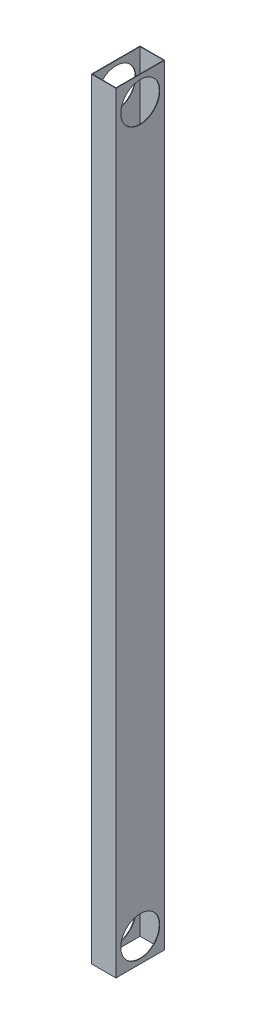
from build123d import *

# Parameters (mm, degrees)
SKETCH2_W           = 51
SKETCH2_H           = 101
SKETCH2_W_2         = 49
SKETCH2_H_2         = 99
BOSS_EXTRUDE2_DEPTH = 1600
SKETCH3_R           = 40.5
CUT_EXTRUDE2_DEPTH  = 52


with BuildPart() as part:
    # Sketch2 → Boss-Extrude2 (new body)
    with BuildSketch(Plane(origin=(0, 0, 0), x_dir=(1, 0, 0), z_dir=(0, 1, 0))):
        Rectangle(SKETCH2_W, SKETCH2_H)
        Rectangle(SKETCH2_W_2, SKETCH2_H_2, mode=Mode.SUBTRACT)
    extrude(amount=BOSS_EXTRUDE2_DEPTH)

    # Sketch3 → Cut-Extrude2 (cut, through all)
    with BuildSketch(Plane.ZY.offset(25.5)):
        with Locations((0, 50)):
            Circle(SKETCH3_R)
        with Locations((0, 1550)):
            Circle(SKETCH3_R)
    extrude(amount=-CUT_EXTRUDE2_DEPTH, mode=Mode.SUBTRACT)


solid = part.part
